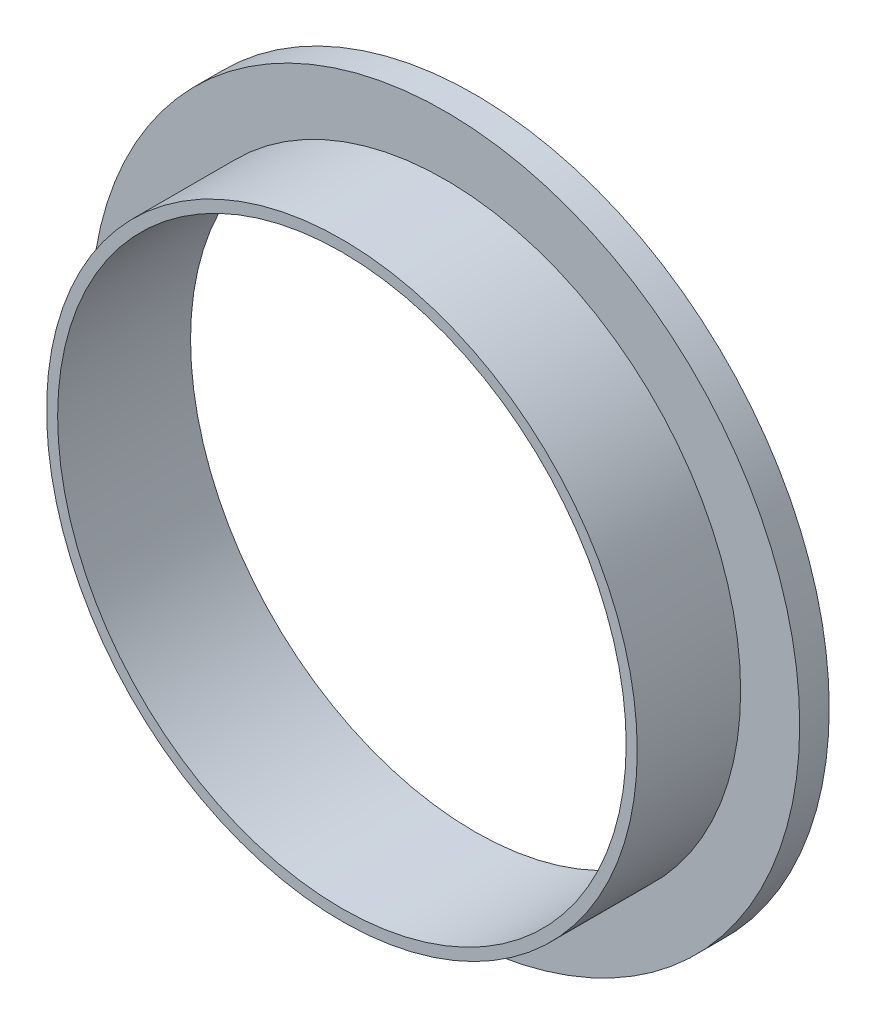
from build123d import *

# Parameters (mm, degrees)
ESQUISSE1_R        = 20
ESQUISSE1_R_2      = 19.25
BOSS_EXTRU_1_DEPTH = 7
BOSS_EXTRU_3_START = -2
ESQUISSE1_4_R      = 24
ESQUISSE1_4_R_2    = 19.25
BOSS_EXTRU_3_DEPTH = 2


with BuildPart() as part:
    # Esquisse1 → Boss.-Extru.1 (new body)
    with BuildSketch(Plane.XY):
        Circle(ESQUISSE1_R)
        Circle(ESQUISSE1_R_2, mode=Mode.SUBTRACT)
    extrude(amount=BOSS_EXTRU_1_DEPTH)

    # Esquisse1_4 → Boss.-Extru.3 (add)
    with BuildSketch(Plane.XY.offset(BOSS_EXTRU_3_START)):
        Circle(ESQUISSE1_4_R)
        Circle(ESQUISSE1_4_R_2, mode=Mode.SUBTRACT)
    extrude(amount=BOSS_EXTRU_3_DEPTH)


solid = part.part
